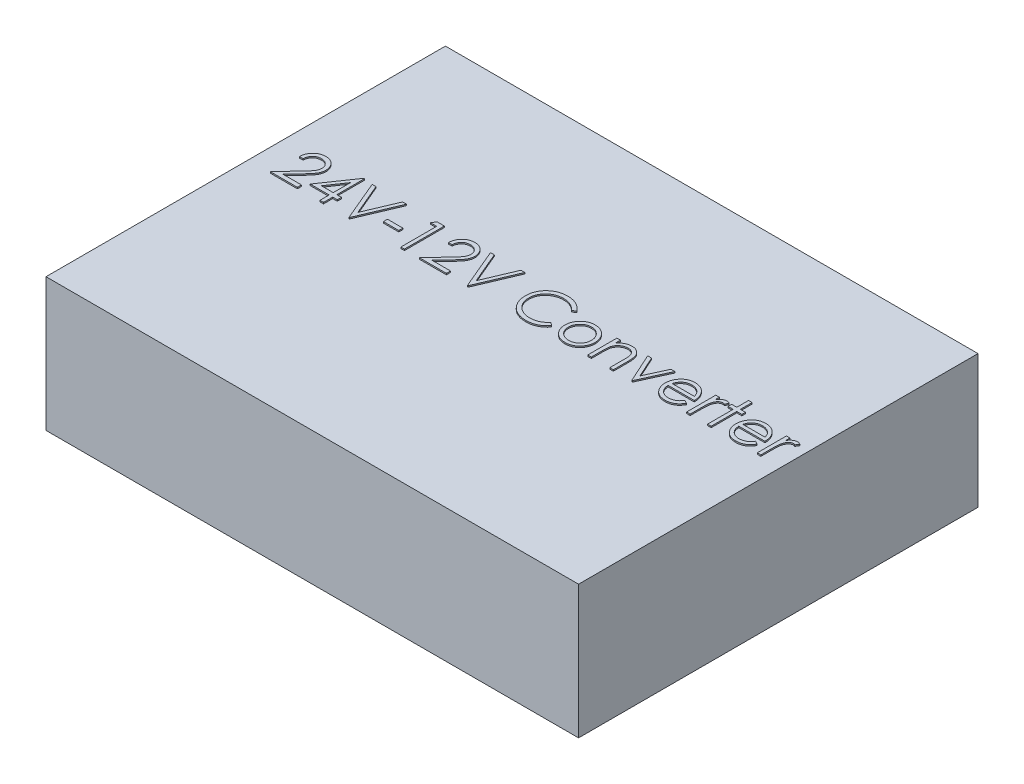
from build123d import *

# Parameters (mm, degrees)
SKETCH1_W           = 101.6
SKETCH1_H           = 76.2
BOSS_EXTRUDE1_DEPTH = 25.4
SKETCH2_W           = 2.930769231
SKETCH2_H           = 0.781538461
BOSS_EXTRUDE2_DEPTH = 0.254


with BuildPart() as part:
    # Sketch1 → Boss-Extrude1 (new body)
    with BuildSketch(Plane(origin=(0, 0, 0), x_dir=(1, 0, 0), z_dir=(0, 1, 0))):
        Rectangle(SKETCH1_W, SKETCH1_H)
    extrude(amount=BOSS_EXTRUDE1_DEPTH)

    # Sketch2 → Boss-Extrude2 (add)
    with BuildSketch(Plane(origin=(0, 25.4, 0), x_dir=(1, 0, 0), z_dir=(0, 1, 0))):
        with BuildLine():
            Line((-45.537178917, 5.672055623), (-46.221025071, 5.672055623))
            add(Edge.make_bspline(
                [(-46.221025071, 5.672055623), (-46.216568126, 5.762779099), (-46.207814806, 5.940957591), (-46.16682293, 6.200742781), (-46.108168792, 6.449056371), (-46.025238255, 6.683904584), (-45.92224573, 6.90736393), (-45.798736356, 7.118546821), (-45.652445745, 7.316647638), (-45.486532798, 7.49982992), (-45.306333647, 7.667878288), (-45.111901858, 7.812996274), (-44.907587828, 7.93560789), (-44.694011422, 8.038110479), (-44.468762995, 8.115050372), (-44.233886602, 8.172138628), (-43.98835031, 8.206485986), (-43.821058605, 8.210177954), (-43.735976994, 8.212055623)],
                knots=[0, 0, 0, 0, 0.000272323, 0.000534836, 0.000787701, 0.001036806, 0.001280626, 0.001524881, 0.001769426, 0.002018016, 0.00226538, 0.002507474, 0.002744387, 0.002979266, 0.003216773, 0.003457051, 0.00370358, 0.00395872, 0.00395872, 0.00395872, 0.00395872], degree=3))
            add(Edge.make_bspline(
                [(-43.735976994, 8.212055623), (-43.652422444, 8.210099555), (-43.488240738, 8.206255951), (-43.24862001, 8.173248225), (-43.020504871, 8.12155068), (-42.80434122, 8.049018259), (-42.601853731, 7.951516163), (-42.411521274, 7.834391236), (-42.231077908, 7.698929774), (-42.068648282, 7.539445757), (-41.919496407, 7.369187995), (-41.790822354, 7.187422902), (-41.680630267, 6.999689428), (-41.588781661, 6.804556029), (-41.52116801, 6.60018539), (-41.469834883, 6.389552909), (-41.440819199, 6.17047832), (-41.43636602, 6.022200619), (-41.434101994, 5.946815239)],
                knots=[0, 0, 0, 0, 0.000250564, 0.00049235, 0.000724148, 0.000951506, 0.001174769, 0.001396771, 0.001621163, 0.001850027, 0.002078347, 0.002299444, 0.002516998, 0.002730754, 0.002945077, 0.003161665, 0.003380352, 0.003606518, 0.003606518, 0.003606518, 0.003606518], degree=3))
            add(Edge.make_bspline(
                [(-41.434101994, 5.946815239), (-41.437788469, 5.840684239), (-41.445096727, 5.630284688), (-41.507612027, 5.321098044), (-41.605249288, 5.021537514), (-41.722809248, 4.780446588), (-41.84140354, 4.586172524), (-41.948274057, 4.426220658), (-42.07338316, 4.253996753), (-42.218551775, 4.070077521), (-42.380776943, 3.873022351), (-42.561528053, 3.662950282), (-42.762094033, 3.442031743), (-42.902864826, 3.291143548), (-42.975808725, 3.212957065)],
                knots=[0, 0, 0, 0, 0.00031812, 0.000630656, 0.000942484, 0.001261306, 0.001432513, 0.001625141, 0.001838259, 0.00207094, 0.00232795, 0.002603949, 0.002902235, 0.003223024, 0.003223024, 0.003223024, 0.003223024], degree=3))
            Line((-42.975808725, 3.212957065), (-44.882335167, 1.178209469))
            Line((-44.882335167, 1.178209469), (-41.336409686, 1.178209469))
            Line((-41.336409686, 1.178209469), (-41.336409686, 0.396671008))
            Line((-41.336409686, 0.396671008), (-46.514101994, 0.396671008))
            Line((-46.514101994, 0.396671008), (-43.558909686, 3.550300815))
            add(Edge.make_bspline(
                [(-43.558909686, 3.550300815), (-43.486959716, 3.625408557), (-43.348758547, 3.769675158), (-43.153289051, 3.980298402), (-42.977726454, 4.175695974), (-42.820934301, 4.355498688), (-42.686313927, 4.522336558), (-42.566849239, 4.67080617), (-42.471129867, 4.807431573), (-42.367246634, 4.965798281), (-42.266632194, 5.159155383), (-42.180172722, 5.39544873), (-42.127453538, 5.63869492), (-42.121129296, 5.803073641), (-42.117948148, 5.885757546)],
                knots=[0, 0, 0, 0, 0.000312026, 0.000599338, 0.000861997, 0.001100083, 0.001314883, 0.001505126, 0.001671571, 0.001815105, 0.002073178, 0.00232331, 0.002568198, 0.002816051, 0.002816051, 0.002816051, 0.002816051], degree=3))
            add(Edge.make_bspline(
                [(-42.117948148, 5.885757546), (-42.11933225, 5.937750762), (-42.122060048, 6.040219407), (-42.146134236, 6.190454802), (-42.182515395, 6.335375911), (-42.234647642, 6.475428505), (-42.30346003, 6.609204467), (-42.387222075, 6.736866638), (-42.483865584, 6.860286614), (-42.595664633, 6.976008937), (-42.718480571, 7.081994876), (-42.848225766, 7.17588217), (-42.98549485, 7.254344463), (-43.129709059, 7.318664877), (-43.280466338, 7.369120993), (-43.438058269, 7.404082814), (-43.602049413, 7.426033822), (-43.71402748, 7.429003819), (-43.771085167, 7.430517162)],
                knots=[0, 0, 0, 0, 0.000155884, 0.000307218, 0.000455306, 0.000603591, 0.000754462, 0.000905611, 0.001061046, 0.001224061, 0.001387476, 0.001547177, 0.001703754, 0.001860911, 0.002020203, 0.00217981, 0.002344531, 0.002515663, 0.002515663, 0.002515663, 0.002515663], degree=3))
            add(Edge.make_bspline(
                [(-43.771085167, 7.430517162), (-43.83067538, 7.428960434), (-43.947700719, 7.425903279), (-44.119518728, 7.404517936), (-44.283426621, 7.367624421), (-44.439836707, 7.317165489), (-44.589013634, 7.25303002), (-44.730231924, 7.17314685), (-44.863174557, 7.077823931), (-44.988091445, 6.969749348), (-45.103183879, 6.849423885), (-45.204305363, 6.715290194), (-45.29266256, 6.569797364), (-45.36975352, 6.413337971), (-45.432358765, 6.244492313), (-45.480197452, 6.063859767), (-45.518051101, 5.872224645), (-45.530697081, 5.739886832), (-45.537178917, 5.672055623)],
                knots=[0, 0, 0, 0, 0.000178757, 0.000351049, 0.000518436, 0.000682079, 0.000843428, 0.00100474, 0.001167813, 0.001333381, 0.001499658, 0.001666348, 0.00183625, 0.002009647, 0.00218884, 0.002375466, 0.002569756, 0.00277406, 0.00277406, 0.00277406, 0.00277406], degree=3))
        make_face()
        Polygon((-36.493008244, 8.212055623), (-36.354101994, 8.212055623), (-36.354101994, 2.936671008), (-35.474871225, 2.936671008), (-35.474871225, 2.155132546), (-36.354101994, 2.155132546), (-36.354101994, 0.396671008), (-37.037948148, 0.396671008), (-37.037948148, 2.155132546), (-40.652563532, 2.155132546), align=None)
        Polygon((-37.037948148, 2.936671008), (-37.037948148, 6.245997931), (-39.309294302, 2.936671008), align=None, mode=Mode.SUBTRACT)
        Polygon((-34.693332763, 8.016671008), (-33.960640455, 8.016671008), (-31.420640455, 2.011646969), (-28.880640455, 8.016671008), (-28.147948148, 8.016671008), (-31.371794302, 0.396671008), (-31.469486609, 0.396671008), align=None)
        with Locations((-25.998717379, 3.327440239)):
            Rectangle(SKETCH2_W, SKETCH2_H)
        Polygon((-22.327623629, 8.016671008), (-20.918717379, 8.016671008), (-20.918717379, 0.396671008), (-21.602563532, 0.396671008), (-21.602563532, 7.235132546), (-22.774871225, 7.235132546), align=None)
        with BuildLine():
            Line((-17.108717379, 5.672055623), (-17.792563532, 5.672055623))
            add(Edge.make_bspline(
                [(-17.792563532, 5.672055623), (-17.788106588, 5.762779099), (-17.779353267, 5.940957591), (-17.738361392, 6.200742781), (-17.679707254, 6.449056371), (-17.596776716, 6.683904584), (-17.493784192, 6.90736393), (-17.370274818, 7.118546821), (-17.223984206, 7.316647638), (-17.058071259, 7.49982992), (-16.877872108, 7.667878288), (-16.68344032, 7.812996274), (-16.479126289, 7.93560789), (-16.265549883, 8.038110479), (-16.040301456, 8.115050372), (-15.805425063, 8.172138628), (-15.559888772, 8.206485986), (-15.392597067, 8.210177954), (-15.307515455, 8.212055623)],
                knots=[0, 0, 0, 0, 0.000272323, 0.000534836, 0.000787701, 0.001036806, 0.001280626, 0.001524881, 0.001769426, 0.002018016, 0.00226538, 0.002507474, 0.002744387, 0.002979266, 0.003216773, 0.003457051, 0.00370358, 0.00395872, 0.00395872, 0.00395872, 0.00395872], degree=3))
            add(Edge.make_bspline(
                [(-15.307515455, 8.212055623), (-15.223960906, 8.210099555), (-15.0597792, 8.206255951), (-14.820158471, 8.173248225), (-14.592043333, 8.12155068), (-14.375879681, 8.049018259), (-14.173392192, 7.951516163), (-13.983059735, 7.834391236), (-13.80261637, 7.698929774), (-13.640186744, 7.539445757), (-13.491034869, 7.369187995), (-13.362360816, 7.187422902), (-13.252168729, 6.999689428), (-13.160320123, 6.804556029), (-13.092706472, 6.60018539), (-13.041373344, 6.389552909), (-13.012357661, 6.17047832), (-13.007904482, 6.022200619), (-13.005640455, 5.946815239)],
                knots=[0, 0, 0, 0, 0.000250564, 0.00049235, 0.000724148, 0.000951506, 0.001174769, 0.001396771, 0.001621163, 0.001850027, 0.002078347, 0.002299444, 0.002516998, 0.002730754, 0.002945077, 0.003161665, 0.003380352, 0.003606518, 0.003606518, 0.003606518, 0.003606518], degree=3))
            add(Edge.make_bspline(
                [(-13.005640455, 5.946815239), (-13.009326931, 5.840684239), (-13.016635188, 5.630284688), (-13.079150488, 5.321098044), (-13.17678775, 5.021537514), (-13.294347709, 4.780446588), (-13.412942002, 4.586172524), (-13.519812518, 4.426220658), (-13.644921621, 4.253996753), (-13.790090237, 4.070077521), (-13.952315404, 3.873022351), (-14.133066514, 3.662950282), (-14.333632495, 3.442031743), (-14.474403288, 3.291143548), (-14.547347186, 3.212957065)],
                knots=[0, 0, 0, 0, 0.00031812, 0.000630656, 0.000942484, 0.001261306, 0.001432513, 0.001625141, 0.001838259, 0.00207094, 0.00232795, 0.002603949, 0.002902235, 0.003223024, 0.003223024, 0.003223024, 0.003223024], degree=3))
            Line((-14.547347186, 3.212957065), (-16.453873629, 1.178209469))
            Line((-16.453873629, 1.178209469), (-12.907948148, 1.178209469))
            Line((-12.907948148, 1.178209469), (-12.907948148, 0.396671008))
            Line((-12.907948148, 0.396671008), (-18.085640455, 0.396671008))
            Line((-18.085640455, 0.396671008), (-15.130448148, 3.550300815))
            add(Edge.make_bspline(
                [(-15.130448148, 3.550300815), (-15.058498177, 3.625408557), (-14.920297008, 3.769675158), (-14.724827513, 3.980298402), (-14.549264915, 4.175695974), (-14.392472763, 4.355498688), (-14.257852388, 4.522336558), (-14.1383877, 4.67080617), (-14.042668328, 4.807431573), (-13.938785095, 4.965798281), (-13.838170656, 5.159155383), (-13.751711183, 5.39544873), (-13.698991999, 5.63869492), (-13.692667757, 5.803073641), (-13.689486609, 5.885757546)],
                knots=[0, 0, 0, 0, 0.000312026, 0.000599338, 0.000861997, 0.001100083, 0.001314883, 0.001505126, 0.001671571, 0.001815105, 0.002073178, 0.00232331, 0.002568198, 0.002816051, 0.002816051, 0.002816051, 0.002816051], degree=3))
            add(Edge.make_bspline(
                [(-13.689486609, 5.885757546), (-13.690870711, 5.937750762), (-13.69359851, 6.040219407), (-13.717672697, 6.190454802), (-13.754053856, 6.335375911), (-13.806186104, 6.475428505), (-13.874998492, 6.609204467), (-13.958760536, 6.736866638), (-14.055404046, 6.860286614), (-14.167203095, 6.976008937), (-14.290019032, 7.081994876), (-14.419764227, 7.17588217), (-14.557033311, 7.254344463), (-14.70124752, 7.318664877), (-14.852004799, 7.369120993), (-15.00959673, 7.404082814), (-15.173587874, 7.426033822), (-15.285565942, 7.429003819), (-15.342623629, 7.430517162)],
                knots=[0, 0, 0, 0, 0.000155884, 0.000307218, 0.000455306, 0.000603591, 0.000754462, 0.000905611, 0.001061046, 0.001224061, 0.001387476, 0.001547177, 0.001703754, 0.001860911, 0.002020203, 0.00217981, 0.002344531, 0.002515663, 0.002515663, 0.002515663, 0.002515663], degree=3))
            add(Edge.make_bspline(
                [(-15.342623629, 7.430517162), (-15.402213842, 7.428960434), (-15.519239181, 7.425903279), (-15.69105719, 7.404517936), (-15.854965082, 7.367624421), (-16.011375168, 7.317165489), (-16.160552095, 7.25303002), (-16.301770385, 7.17314685), (-16.434713018, 7.077823931), (-16.559629906, 6.969749348), (-16.674722341, 6.849423885), (-16.775843825, 6.715290194), (-16.864201021, 6.569797364), (-16.941291981, 6.413337971), (-17.003897226, 6.244492313), (-17.051735914, 6.063859767), (-17.089589563, 5.872224645), (-17.102235542, 5.739886832), (-17.108717379, 5.672055623)],
                knots=[0, 0, 0, 0, 0.000178757, 0.000351049, 0.000518436, 0.000682079, 0.000843428, 0.00100474, 0.001167813, 0.001333381, 0.001499658, 0.001666348, 0.00183625, 0.002009647, 0.00218884, 0.002375466, 0.002569756, 0.00277406, 0.00277406, 0.00277406, 0.00277406], degree=3))
        make_face()
        Polygon((-12.126409686, 8.016671008), (-11.393717379, 8.016671008), (-8.853717379, 2.011646969), (-6.313717379, 8.016671008), (-5.581025071, 8.016671008), (-8.804871225, 0.396671008), (-8.902563532, 0.396671008), align=None)
        with BuildLine():
            Line((5.751282621, 6.618449854), (5.152917237, 6.160517162))
            add(Edge.make_bspline(
                [(5.152917237, 6.160517162), (5.110232417, 6.211388216), (5.025438261, 6.312444472), (4.889020226, 6.454349652), (4.746849221, 6.58729745), (4.598979591, 6.711921199), (4.442749737, 6.823862843), (4.281944227, 6.92895593), (4.113873054, 7.023155977), (3.881459277, 7.137375393), (3.577425962, 7.256565593), (3.194695484, 7.356503485), (2.795165606, 7.420122159), (2.522592547, 7.427012471), (2.383950891, 7.430517162)],
                knots=[0, 0, 0, 0, 0.000199176, 0.000395666, 0.000590059, 0.000782959, 0.000975315, 0.001166267, 0.00135901, 0.001552886, 0.00194293, 0.002336139, 0.002737684, 0.00315335, 0.00315335, 0.00315335, 0.00315335], degree=3))
            add(Edge.make_bspline(
                [(2.383950891, 7.430517162), (2.307569536, 7.429637678), (2.155515718, 7.427886872), (1.929858184, 7.404789291), (1.708414342, 7.372325456), (1.491328235, 7.324155467), (1.278876194, 7.263255079), (1.069669307, 7.190483178), (0.866736516, 7.100447784), (0.667270523, 7.000934372), (0.47616264, 6.888534049), (0.295339936, 6.765931838), (0.125461903, 6.63449969), (-0.033605841, 6.493744996), (-0.182025911, 6.344301642), (-0.318722856, 6.18457699), (-0.443223664, 6.015081686), (-0.557996158, 5.838050782), (-0.660785024, 5.653999933), (-0.746847218, 5.462247922), (-0.82305837, 5.266078418), (-0.883363578, 5.063275033), (-0.931096383, 4.855264783), (-0.964031467, 4.641489411), (-0.986866368, 4.422395514), (-0.988608467, 4.273894096), (-0.989486609, 4.199038796)],
                knots=[0, 0, 0, 0, 0.000229048, 0.00045597, 0.000679837, 0.000900206, 0.001122459, 0.001342606, 0.001564087, 0.001787996, 0.002011045, 0.002228658, 0.002442997, 0.002654947, 0.002865424, 0.003074369, 0.003285023, 0.003495877, 0.003707001, 0.003916708, 0.004125919, 0.004337919, 0.00455084, 0.004765657, 0.004986501, 0.005210971, 0.005210971, 0.005210971, 0.005210971], degree=3))
            add(Edge.make_bspline(
                [(-0.989486609, 4.199038796), (-0.986739449, 4.086412323), (-0.981345764, 3.865285181), (-0.933343391, 3.541390309), (-0.860398021, 3.231102442), (-0.751071536, 2.936361185), (-0.616264918, 2.653532131), (-0.445923929, 2.387400685), (-0.248638782, 2.133945193), (-0.021618475, 1.899155689), (0.22745933, 1.684677236), (0.494699069, 1.495808827), (0.779435147, 1.338368997), (1.078523697, 1.207357365), (1.394266265, 1.106649861), (1.726095063, 1.035753112), (2.073288378, 0.98950585), (2.310530329, 0.985078221), (2.431270602, 0.982824854)],
                knots=[0, 0, 0, 0, 0.000337689, 0.000663007, 0.000980291, 0.001292238, 0.001604234, 0.001918459, 0.00223816, 0.002566349, 0.002896488, 0.003222997, 0.003546206, 0.003870912, 0.004201103, 0.00453853, 0.004887849, 0.005249876, 0.005249876, 0.005249876, 0.005249876], degree=3))
            add(Edge.make_bspline(
                [(2.431270602, 0.982824854), (2.564299885, 0.986501569), (2.826133337, 0.993738223), (3.210111726, 1.055044931), (3.577691307, 1.154448741), (3.928891853, 1.293563646), (4.262723282, 1.474408644), (4.579708011, 1.693642309), (4.880113602, 1.95335005), (5.060753936, 2.151651032), (5.152917237, 2.252824854)],
                knots=[0, 0, 0, 0, 0.000398895, 0.000785121, 0.001163193, 0.001539336, 0.001915653, 0.002299692, 0.002693579, 0.003103877, 0.003103877, 0.003103877, 0.003103877], degree=3))
            Line((5.152917237, 2.252824854), (5.751282621, 1.799471489))
            add(Edge.make_bspline(
                [(5.751282621, 1.799471489), (5.703128337, 1.737339202), (5.607050423, 1.613372238), (5.451476112, 1.438609259), (5.287586681, 1.274226187), (5.114164821, 1.121548338), (4.933205515, 0.977520615), (4.741459509, 0.846234914), (4.541447501, 0.72585876), (4.333847179, 0.615636713), (4.118879113, 0.51784545), (3.896800886, 0.434126104), (3.668569748, 0.362008487), (3.434175264, 0.302677128), (3.193131244, 0.25636694), (2.946307526, 0.225408676), (2.693171398, 0.204199137), (2.522393218, 0.202266017), (2.435849929, 0.201286392)],
                knots=[0, 0, 0, 0, 0.00023577, 0.00047041, 0.000701393, 0.000931724, 0.001163205, 0.001394807, 0.001628318, 0.001863212, 0.002099574, 0.002336295, 0.002574782, 0.002817275, 0.003061263, 0.003310615, 0.003563259, 0.003822826, 0.003822826, 0.003822826, 0.003822826], degree=3))
            add(Edge.make_bspline(
                [(2.435849929, 0.201286392), (2.353894288, 0.201856788), (2.191837157, 0.202984674), (1.952571875, 0.221255621), (1.719640274, 0.246183334), (1.493708088, 0.283717562), (1.273542394, 0.328010097), (1.061139064, 0.387383518), (0.854408006, 0.453893418), (0.65417979, 0.532063703), (0.460284101, 0.620273221), (0.273346317, 0.719967986), (0.093452416, 0.830309646), (-0.081166243, 0.948865983), (-0.247930125, 1.079445137), (-0.408284372, 1.220233639), (-0.563128163, 1.370756965), (-0.658928294, 1.479298103), (-0.707094782, 1.533870527)],
                knots=[0, 0, 0, 0, 0.0002458, 0.000486039, 0.000719505, 0.000948369, 0.001172896, 0.001392858, 0.001609596, 0.00182418, 0.002037297, 0.002248306, 0.002459308, 0.002670156, 0.002881148, 0.003094244, 0.003310126, 0.003528424, 0.003528424, 0.003528424, 0.003528424], degree=3))
            add(Edge.make_bspline(
                [(-0.707094782, 1.533870527), (-0.784243241, 1.628665915), (-0.937608753, 1.817112239), (-1.133825241, 2.122534861), (-1.30178649, 2.441417076), (-1.43758778, 2.775434178), (-1.543751216, 3.123836661), (-1.617297704, 3.486800153), (-1.665089483, 3.863985672), (-1.67055474, 4.120533195), (-1.673332763, 4.250937835)],
                knots=[0, 0, 0, 0, 0.000366426, 0.000728427, 0.001086882, 0.001446309, 0.001808466, 0.002177883, 0.00255617, 0.002947238, 0.002947238, 0.002947238, 0.002947238], degree=3))
            add(Edge.make_bspline(
                [(-1.673332763, 4.250937835), (-1.669946885, 4.388000851), (-1.66328538, 4.657663778), (-1.60668882, 5.053411642), (-1.515643326, 5.432564116), (-1.386327814, 5.794413411), (-1.222377307, 6.140862764), (-1.019845079, 6.469265616), (-0.781084043, 6.781722191), (-0.507966768, 7.07349145), (-0.208463026, 7.340277126), (0.112271077, 7.574986633), (0.453607773, 7.770314482), (0.811786639, 7.933591841), (1.189489751, 8.059092072), (1.585911258, 8.146946724), (2.000306267, 8.201630275), (2.283035319, 8.208543156), (2.426691275, 8.212055623)],
                knots=[0, 0, 0, 0, 0.000411021, 0.000808659, 0.001196655, 0.001579034, 0.001959341, 0.002344444, 0.002734312, 0.003137157, 0.003541534, 0.003936009, 0.004327172, 0.004719298, 0.005115115, 0.005518766, 0.005935868, 0.006366714, 0.006366714, 0.006366714, 0.006366714], degree=3))
            add(Edge.make_bspline(
                [(2.426691275, 8.212055623), (2.514243926, 8.211005939), (2.68754558, 8.208928196), (2.943909926, 8.188667395), (3.193502649, 8.154892058), (3.436495701, 8.108919358), (3.674071226, 8.051862275), (3.904413465, 7.977533968), (4.128874034, 7.892545863), (4.346037303, 7.79466486), (4.554861335, 7.684791555), (4.755281091, 7.564143826), (4.945704584, 7.432871243), (5.127471734, 7.292090273), (5.297541885, 7.138822552), (5.460743732, 6.977283786), (5.611534994, 6.802821003), (5.704614807, 6.680019404), (5.751282621, 6.618449854)],
                knots=[0, 0, 0, 0, 0.000262619, 0.000519828, 0.000770894, 0.001017881, 0.001261486, 0.001503344, 0.001743462, 0.001981214, 0.002217458, 0.002450969, 0.002682571, 0.002910967, 0.003140157, 0.003368981, 0.003599453, 0.003831196, 0.003831196, 0.003831196, 0.003831196], degree=3))
        make_face()
        with BuildLine():
            add(Edge.make_bspline(
                [(9.808566275, 6.062824854), (9.913050132, 6.060600051), (10.117917441, 6.056237756), (10.417944895, 6.009614316), (10.704337448, 5.938318626), (10.978191958, 5.839755968), (11.23600115, 5.707642693), (11.481520259, 5.549997322), (11.714076147, 5.363236361), (11.853463427, 5.218765366), (11.924215314, 5.145433027)],
                knots=[0, 0, 0, 0, 0.000313222, 0.000614152, 0.000908474, 0.00119773, 0.001485127, 0.001775589, 0.002071911, 0.002377372, 0.002377372, 0.002377372, 0.002377372], degree=3))
            add(Edge.make_bspline(
                [(11.924215314, 5.145433027), (11.985136025, 5.075298578), (12.105798464, 4.936386975), (12.260518686, 4.711149326), (12.393806769, 4.477890021), (12.500623844, 4.233511556), (12.584846667, 3.980147272), (12.644643411, 3.716926322), (12.680211253, 3.444430011), (12.685007426, 3.259364513), (12.687436468, 3.165637354)],
                knots=[0, 0, 0, 0, 0.000278504, 0.000551617, 0.000818199, 0.001083383, 0.001350318, 0.001618043, 0.001892008, 0.002173139, 0.002173139, 0.002173139, 0.002173139], degree=3))
            add(Edge.make_bspline(
                [(12.687436468, 3.165637354), (12.685299956, 3.071366943), (12.68107811, 2.885084214), (12.641141436, 2.610722051), (12.579025186, 2.344686466), (12.490128442, 2.088091253), (12.376137358, 1.840152069), (12.237038204, 1.60195185), (12.071854855, 1.373020634), (11.884611867, 1.155302346), (11.677670354, 0.95464333), (11.453171768, 0.779757212), (11.215527844, 0.629922921), (10.9615786, 0.509229925), (10.6936431, 0.414067663), (10.411143426, 0.347229342), (10.114518445, 0.306817905), (9.911984894, 0.301628525), (9.808566275, 0.2989787)],
                knots=[0, 0, 0, 0, 0.000282656, 0.000558541, 0.00082993, 0.001101225, 0.001371698, 0.001647376, 0.001927386, 0.002217458, 0.002507856, 0.002790606, 0.003069716, 0.003348959, 0.003632355, 0.00392114, 0.004218404, 0.004528576, 0.004528576, 0.004528576, 0.004528576], degree=3))
            add(Edge.make_bspline(
                [(9.808566275, 0.2989787), (9.704640972, 0.301637419), (9.501098014, 0.306844653), (9.203426019, 0.347072338), (8.920420049, 0.41403686), (8.652133786, 0.509542658), (8.397092719, 0.629926779), (8.158071831, 0.779304229), (7.933390873, 0.954695195), (7.726405581, 1.155288293), (7.539174331, 1.373024255), (7.373987953, 1.60195091), (7.234889586, 1.840152313), (7.120898296, 2.088091187), (7.032001607, 2.344686484), (6.969885342, 2.610722047), (6.929948673, 2.885084215), (6.925726826, 3.071366943), (6.923590314, 3.165637354)],
                knots=[0, 0, 0, 0, 0.000311697, 0.000610475, 0.000899259, 0.001182655, 0.001463276, 0.001743681, 0.002026431, 0.002316828, 0.002606901, 0.00288691, 0.003162588, 0.003433062, 0.003704357, 0.003975746, 0.004251631, 0.004534287, 0.004534287, 0.004534287, 0.004534287], degree=3))
            add(Edge.make_bspline(
                [(6.923590314, 3.165637354), (6.926035921, 3.258855091), (6.930877803, 3.44341019), (6.966409882, 3.715394248), (7.025973368, 3.978169706), (7.110297151, 4.230556028), (7.218098796, 4.473863578), (7.349513942, 4.707699238), (7.505812405, 4.931918392), (7.62599494, 5.070650464), (7.686811468, 5.1408537)],
                knots=[0, 0, 0, 0, 0.000279606, 0.000553571, 0.000821296, 0.001086782, 0.00135057, 0.001618481, 0.001890342, 0.002168846, 0.002168846, 0.002168846, 0.002168846], degree=3))
            add(Edge.make_bspline(
                [(7.686811468, 5.1408537), (7.757456686, 5.214821996), (7.896392938, 5.360293666), (8.130106454, 5.54651019), (8.375021573, 5.707436043), (8.635679841, 5.83692426), (8.909309377, 5.938898404), (9.197169557, 6.009798183), (9.498215107, 6.056069773), (9.704084911, 6.06055072), (9.808566275, 6.062824854)],
                knots=[0, 0, 0, 0, 0.000306538, 0.00060286, 0.000894151, 0.001184275, 0.001474058, 0.001768381, 0.00207233, 0.002385553, 0.002385553, 0.002385553, 0.002385553], degree=3))
        make_face()
        with BuildLine():
            add(Edge.make_bspline(
                [(9.805513391, 5.3789787), (9.731626363, 5.376878646), (9.585759688, 5.372732751), (9.371050764, 5.341199221), (9.164352486, 5.291239227), (8.965272705, 5.220255539), (8.77448277, 5.128600221), (8.591800014, 5.016023734), (8.416687102, 4.884017126), (8.252569581, 4.732786967), (8.101949804, 4.567587556), (7.970280609, 4.391569129), (7.858320806, 4.207586741), (7.76505166, 4.01544907), (7.695585154, 3.813209014), (7.645134173, 3.603156897), (7.613630393, 3.384864762), (7.609523477, 3.236468488), (7.607436468, 3.161058027)],
                knots=[0, 0, 0, 0, 0.000221592, 0.000437463, 0.0006496, 0.000858656, 0.001070304, 0.001283405, 0.001501382, 0.001727177, 0.001951943, 0.00217114, 0.002385544, 0.002597192, 0.002810566, 0.00302567, 0.003244564, 0.00347073, 0.00347073, 0.00347073, 0.00347073], degree=3))
            add(Edge.make_bspline(
                [(7.607436468, 3.161058027), (7.610934752, 3.063626471), (7.617878193, 2.870243051), (7.674342908, 2.585448549), (7.768801037, 2.312038917), (7.896353915, 2.051616957), (8.056169739, 1.810667597), (8.244464439, 1.59584568), (8.459217158, 1.410383999), (8.697867938, 1.256501701), (8.955542196, 1.13423389), (9.228243101, 1.047585834), (9.512666555, 0.991259464), (9.707043461, 0.985660997), (9.805513391, 0.982824854)],
                knots=[0, 0, 0, 0, 0.000292125, 0.000579814, 0.000867033, 0.001157847, 0.001447425, 0.001731888, 0.002012193, 0.002295869, 0.002581281, 0.002865126, 0.003152527, 0.003447608, 0.003447608, 0.003447608, 0.003447608], degree=3))
            add(Edge.make_bspline(
                [(9.805513391, 0.982824854), (9.903977657, 0.985677521), (10.098343383, 0.991308607), (10.382371648, 1.047302152), (10.654327209, 1.13461355), (10.91173383, 1.25636419), (11.150275978, 1.410968362), (11.366573208, 1.594798417), (11.553260184, 1.811236573), (11.712917919, 2.051936108), (11.842559684, 2.311635183), (11.936575683, 2.585499011), (11.993176142, 2.870230199), (12.00010126, 3.063622165), (12.003590314, 3.161058027)],
                knots=[0, 0, 0, 0, 0.000295081, 0.000582483, 0.000864874, 0.001150287, 0.001433963, 0.001715425, 0.001998883, 0.002288461, 0.002579951, 0.00286717, 0.003154859, 0.003446984, 0.003446984, 0.003446984, 0.003446984], degree=3))
            add(Edge.make_bspline(
                [(12.003590314, 3.161058027), (12.001504023, 3.236468938), (11.997398521, 3.384866099), (11.965884456, 3.603151784), (11.915471538, 3.813227774), (11.84586476, 4.01537985), (11.753000879, 4.208084217), (11.638882032, 4.391028937), (11.507750485, 4.568197303), (11.355313211, 4.732252944), (11.191366999, 4.88407608), (11.016183116, 5.016074922), (10.833771248, 5.128105459), (10.643535591, 5.221039503), (10.444430287, 5.290593426), (10.238021623, 5.341487693), (10.024228785, 5.372599492), (9.878884811, 5.376838697), (9.805513391, 5.3789787)],
                knots=[0, 0, 0, 0, 0.000226166, 0.00044506, 0.000660164, 0.000873539, 0.001085186, 0.001300388, 0.001519585, 0.00174538, 0.001971175, 0.002189151, 0.002402253, 0.002612525, 0.00282302, 0.003033674, 0.003249546, 0.003469613, 0.003469613, 0.003469613, 0.003469613], degree=3))
        make_face(mode=Mode.SUBTRACT)
        with BuildLine():
            Line((14.055128775, 5.965132546), (14.738974929, 5.965132546))
            Line((14.738974929, 5.965132546), (14.738974929, 4.960733508))
            add(Edge.make_bspline(
                [(14.738974929, 4.960733508), (14.811991152, 5.051831093), (14.95368168, 5.228609135), (15.189649857, 5.460955072), (15.439028291, 5.65242439), (15.700289796, 5.805050365), (15.973789035, 5.920105019), (16.257858868, 6.003197703), (16.554200029, 6.053021244), (16.755726031, 6.059531403), (16.857676852, 6.062824854)],
                knots=[0, 0, 0, 0, 0.000350035, 0.000679255, 0.000990664, 0.001290955, 0.001584389, 0.001878565, 0.00217719, 0.00248294, 0.00248294, 0.00248294, 0.00248294], degree=3))
            add(Edge.make_bspline(
                [(16.857676852, 6.062824854), (16.960722404, 6.059025314), (17.162407405, 6.051588698), (17.456056213, 5.992769502), (17.730318288, 5.89230469), (17.984215721, 5.754682982), (18.213092682, 5.58354546), (18.414097073, 5.384167547), (18.580350772, 5.154835845), (18.691814745, 4.942078574), (18.765240298, 4.753344684), (18.81146613, 4.591698903), (18.850722152, 4.411609671), (18.884754701, 4.213621194), (18.907782584, 3.996346277), (18.925944945, 3.760675587), (18.938961416, 3.506685463), (18.93947785, 3.331019149), (18.93974416, 3.240433027)],
                knots=[0, 0, 0, 0, 0.000308979, 0.000604747, 0.000894003, 0.001182238, 0.001467988, 0.001748621, 0.00202829, 0.00231437, 0.002466594, 0.002635174, 0.002818125, 0.003019384, 0.00323751, 0.003473295, 0.003728503, 0.004000227, 0.004000227, 0.004000227, 0.004000227], degree=3))
            Line((18.93974416, 3.240433027), (18.93974416, 0.396671008))
            Line((18.93974416, 0.396671008), (18.255898006, 0.396671008))
            Line((18.255898006, 0.396671008), (18.255898006, 3.016046008))
            add(Edge.make_bspline(
                [(18.255898006, 3.016046008), (18.255477365, 3.091859445), (18.254672749, 3.236877648), (18.25213497, 3.444509636), (18.246017619, 3.632803272), (18.237421578, 3.801308398), (18.224839803, 3.949863207), (18.211727674, 4.078770261), (18.195693068, 4.187865894), (18.181404668, 4.253539587), (18.174996564, 4.282993123)],
                knots=[0, 0, 0, 0, 0.000227445, 0.000435064, 0.000622915, 0.000792598, 0.000941165, 0.00107012, 0.001181299, 0.001271708, 0.001271708, 0.001271708, 0.001271708], degree=3))
            add(Edge.make_bspline(
                [(18.174996564, 4.282993123), (18.151863264, 4.369450046), (18.107338819, 4.535852873), (17.997319118, 4.761566749), (17.85838653, 4.953586804), (17.688791784, 5.110725838), (17.490173053, 5.233017773), (17.263081503, 5.317869641), (17.009708576, 5.370940261), (16.831499892, 5.376224474), (16.738614352, 5.3789787)],
                knots=[0, 0, 0, 0, 0.000267998, 0.000515814, 0.00074846, 0.000975289, 0.001204891, 0.001443583, 0.001699242, 0.001977562, 0.001977562, 0.001977562, 0.001977562], degree=3))
            add(Edge.make_bspline(
                [(16.738614352, 5.3789787), (16.683602995, 5.37794237), (16.574736941, 5.375891499), (16.41330186, 5.355314673), (16.25671266, 5.321659407), (16.103397805, 5.276225402), (15.956423694, 5.213823547), (15.811068294, 5.143002461), (15.672804996, 5.054723211), (15.5386856, 4.956336773), (15.413907431, 4.847307184), (15.297804019, 4.732257137), (15.194306958, 4.609737108), (15.100540299, 4.481721222), (15.019597909, 4.346451335), (14.9489429, 4.205232473), (14.888993759, 4.057878766), (14.859204583, 3.955607347), (14.844299448, 3.904435431)],
                knots=[0, 0, 0, 0, 0.000164969, 0.000326469, 0.000487239, 0.000645143, 0.000805303, 0.000965725, 0.001129631, 0.001296628, 0.001464349, 0.001626253, 0.001786522, 0.001944986, 0.002101794, 0.002258802, 0.002418386, 0.002578197, 0.002578197, 0.002578197, 0.002578197], degree=3))
            add(Edge.make_bspline(
                [(14.844299448, 3.904435431), (14.835722271, 3.866868389), (14.817050203, 3.785086903), (14.796882937, 3.650878196), (14.778578445, 3.495626193), (14.763257981, 3.319512063), (14.753884474, 3.121919203), (14.743664101, 2.903691465), (14.739943231, 2.663958671), (14.739306735, 2.497055214), (14.738974929, 2.410048412)],
                knots=[0, 0, 0, 0, 0.000115567, 0.000251583, 0.000406838, 0.000584562, 0.000781763, 0.001000236, 0.001239931, 0.001500958, 0.001500958, 0.001500958, 0.001500958], degree=3))
            Line((14.738974929, 2.410048412), (14.738974929, 0.396671008))
            Line((14.738974929, 0.396671008), (14.055128775, 0.396671008))
            Line((14.055128775, 0.396671008), (14.055128775, 5.965132546))
        make_face()
        Polygon((19.916667237, 5.965132546), (20.656991756, 5.965132546), (22.505513391, 1.910901777), (24.354035025, 5.965132546), (25.094359545, 5.965132546), (22.554359545, 0.396671008), (22.456667237, 0.396671008), align=None)
        with BuildLine():
            Line((30.836835506, 2.155132546), (31.444359545, 1.836106104))
            add(Edge.make_bspline(
                [(31.444359545, 1.836106104), (31.3959473, 1.750232337), (31.301756244, 1.583155993), (31.139775187, 1.353615771), (30.969975303, 1.147118744), (30.784691807, 0.969181611), (30.589468106, 0.814057167), (30.383221583, 0.678338817), (30.1648785, 0.56269221), (29.934428528, 0.465259564), (29.689936362, 0.39034518), (29.430809518, 0.337431419), (29.156551577, 0.304723617), (28.968563608, 0.300924196), (28.872304256, 0.2989787)],
                knots=[0, 0, 0, 0, 0.000295567, 0.000575056, 0.000841637, 0.001096402, 0.001344091, 0.001588798, 0.001835992, 0.002084334, 0.002338302, 0.002601745, 0.002876852, 0.003165547, 0.003165547, 0.003165547, 0.003165547], degree=3))
            add(Edge.make_bspline(
                [(28.872304256, 0.2989787), (28.765315151, 0.301476265), (28.556610401, 0.30634829), (28.252812437, 0.348350741), (27.966780675, 0.416870562), (27.698531195, 0.512589826), (27.448720919, 0.637617315), (27.216853344, 0.789929101), (27.001709119, 0.968742752), (26.810067841, 1.175607124), (26.637542588, 1.396983271), (26.485304088, 1.627664368), (26.35803391, 1.867070017), (26.254505084, 2.113676129), (26.170892207, 2.365928377), (26.112617269, 2.626121915), (26.079024503, 2.89355253), (26.073876768, 3.074467301), (26.071282621, 3.165637354)],
                knots=[0, 0, 0, 0, 0.000320847, 0.00062588, 0.000917989, 0.001201899, 0.001478371, 0.001753986, 0.002032489, 0.002315413, 0.002598163, 0.002873778, 0.003143509, 0.003410288, 0.003675296, 0.003939705, 0.004208935, 0.004482441, 0.004482441, 0.004482441, 0.004482441], degree=3))
            add(Edge.make_bspline(
                [(26.071282621, 3.165637354), (26.073588523, 3.251187813), (26.078158517, 3.420737526), (26.106963831, 3.671687083), (26.158014115, 3.915589028), (26.228066569, 4.152646026), (26.318529567, 4.382461164), (26.42919857, 4.605174308), (26.560245976, 4.82054847), (26.661423625, 4.956409007), (26.712388391, 5.024844085)],
                knots=[0, 0, 0, 0, 0.000256665, 0.000508676, 0.000756552, 0.00100335, 0.001249392, 0.00149651, 0.001748614, 0.002004492, 0.002004492, 0.002004492, 0.002004492], degree=3))
            add(Edge.make_bspline(
                [(26.712388391, 5.024844085), (26.781420546, 5.107290025), (26.917298092, 5.269570227), (27.147109357, 5.482795953), (27.395957213, 5.661416972), (27.660723097, 5.809478223), (27.94448422, 5.921979134), (28.243426162, 6.005815642), (28.560952839, 6.052794054), (28.778025348, 6.059429624), (28.889095121, 6.062824854)],
                knots=[0, 0, 0, 0, 0.000322372, 0.000634532, 0.000937434, 0.001239442, 0.001542171, 0.001851029, 0.002169017, 0.002502205, 0.002502205, 0.002502205, 0.002502205], degree=3))
            add(Edge.make_bspline(
                [(28.889095121, 6.062824854), (29.003281051, 6.059876896), (29.227287815, 6.054093675), (29.553929175, 6.000478629), (29.862997935, 5.915455639), (30.154370416, 5.795377958), (30.428076159, 5.640453448), (30.682336072, 5.448556067), (30.921498508, 5.22557726), (31.060636614, 5.054098501), (31.131438871, 4.966839277)],
                knots=[0, 0, 0, 0, 0.000342335, 0.000671583, 0.000990084, 0.001302184, 0.001614583, 0.001930863, 0.002255894, 0.002592658, 0.002592658, 0.002592658, 0.002592658], degree=3))
            add(Edge.make_bspline(
                [(31.131438871, 4.966839277), (31.179612377, 4.901081766), (31.275638731, 4.770004444), (31.39591956, 4.556271811), (31.50032966, 4.332656174), (31.583785993, 4.095542899), (31.651363421, 3.847741413), (31.700255124, 3.587480215), (31.728927265, 3.314836808), (31.734563228, 3.129068707), (31.737436468, 3.034363315)],
                knots=[0, 0, 0, 0, 0.00024435, 0.000487074, 0.000734305, 0.00098392, 0.001240162, 0.001504214, 0.001777465, 0.002061645, 0.002061645, 0.002061645, 0.002061645], degree=3))
            Line((31.737436468, 3.034363315), (26.755128775, 3.034363315))
            add(Edge.make_bspline(
                [(26.755128775, 3.034363315), (26.758480718, 2.96099259), (26.765072179, 2.816712019), (26.795802863, 2.605592771), (26.844241621, 2.404482809), (26.912318838, 2.214890586), (26.99476037, 2.034339851), (27.095748701, 1.864169931), (27.216230816, 1.705155923), (27.350616482, 1.555875469), (27.500201643, 1.422937469), (27.65757151, 1.303952745), (27.824979786, 1.204227417), (28.001106471, 1.123281486), (28.185666757, 1.059912878), (28.378718793, 1.016657794), (28.579882692, 0.987686321), (28.717011633, 0.984464879), (28.786823487, 0.982824854)],
                knots=[0, 0, 0, 0, 0.000220237, 0.000433086, 0.00063893, 0.000839772, 0.00103647, 0.001233593, 0.001432031, 0.001634104, 0.001835155, 0.002031456, 0.002225176, 0.002418462, 0.002612031, 0.002809392, 0.003011234, 0.003220558, 0.003220558, 0.003220558, 0.003220558], degree=3))
            add(Edge.make_bspline(
                [(28.786823487, 0.982824854), (28.855079414, 0.98414868), (28.990512267, 0.986775405), (29.192204648, 1.012317451), (29.390628419, 1.053618451), (29.584962331, 1.109984658), (29.771262287, 1.178731976), (29.94379117, 1.261687341), (30.102461811, 1.353453361), (30.250762178, 1.45841271), (30.394608169, 1.586881963), (30.537303526, 1.747197447), (30.690305839, 1.936799436), (30.786077467, 2.079501715), (30.836835506, 2.155132546)],
                knots=[0, 0, 0, 0, 0.000204686, 0.000406136, 0.000608808, 0.000812192, 0.001012644, 0.001203816, 0.00138577, 0.001561973, 0.001747936, 0.001962948, 0.002205152, 0.002478266, 0.002478266, 0.002478266, 0.002478266], degree=3))
        make_face()
        with BuildLine():
            add(Edge.make_bspline(
                [(31.053590314, 3.718209469), (31.02856052, 3.808915497), (30.980386223, 3.983495403), (30.879723053, 4.225247284), (30.76635587, 4.440104943), (30.632196558, 4.62642403), (30.480191218, 4.791894535), (30.304615134, 4.936497283), (30.107723275, 5.065857563), (29.890533374, 5.175046719), (29.660536117, 5.26798864), (29.419730636, 5.330309606), (29.174023109, 5.373002381), (29.007832463, 5.37697808), (28.924203295, 5.3789787)],
                knots=[0, 0, 0, 0, 0.000282033, 0.000542822, 0.000783913, 0.001009269, 0.001229627, 0.001456143, 0.001689843, 0.001934922, 0.002184363, 0.002432442, 0.002679876, 0.00293051, 0.00293051, 0.00293051, 0.00293051], degree=3))
            add(Edge.make_bspline(
                [(28.924203295, 5.3789787), (28.855951088, 5.377647004), (28.721030826, 5.37501452), (28.522255358, 5.35004241), (28.331364127, 5.308764119), (28.146948616, 5.252234699), (27.971425468, 5.176886828), (27.801184287, 5.088531346), (27.640553824, 4.98067224), (27.540097632, 4.898465819), (27.489347525, 4.856935431)],
                knots=[0, 0, 0, 0, 0.000204686, 0.00040462, 0.000599826, 0.00079005, 0.000982267, 0.001172087, 0.001364715, 0.001561389, 0.001561389, 0.001561389, 0.001561389], degree=3))
            add(Edge.make_bspline(
                [(27.489347525, 4.856935431), (27.453003866, 4.824072949), (27.379453156, 4.757567296), (27.281175792, 4.642985995), (27.187078649, 4.519429737), (27.101443668, 4.382171494), (27.022897608, 4.232774255), (26.949397315, 4.072498147), (26.883241755, 3.900126932), (26.846021081, 3.78000865), (26.826871564, 3.718209469)],
                knots=[0, 0, 0, 0, 0.000146856, 0.000297201, 0.000451983, 0.000612491, 0.000781837, 0.000958067, 0.001141195, 0.001335252, 0.001335252, 0.001335252, 0.001335252], degree=3))
            Line((26.826871564, 3.718209469), (31.053590314, 3.718209469))
        make_face(mode=Mode.SUBTRACT)
        with BuildLine():
            Line((32.90974416, 5.965132546), (33.593590314, 5.965132546))
            Line((33.593590314, 5.965132546), (33.593590314, 5.145433027))
            add(Edge.make_bspline(
                [(33.593590314, 5.145433027), (33.644075554, 5.221754573), (33.740628184, 5.367718937), (33.901111762, 5.560764673), (34.0654933, 5.720599717), (34.234559737, 5.847970235), (34.409554343, 5.943357654), (34.586636506, 6.013228776), (34.768592244, 6.054545102), (34.890864776, 6.06006124), (34.952123968, 6.062824854)],
                knots=[0, 0, 0, 0, 0.000274369, 0.000524729, 0.000751435, 0.000960864, 0.001157609, 0.001347533, 0.001530484, 0.001714171, 0.001714171, 0.001714171, 0.001714171], degree=3))
            add(Edge.make_bspline(
                [(34.952123968, 6.062824854), (34.999642998, 6.060232907), (35.097416492, 6.054899809), (35.245424302, 6.017429385), (35.397918903, 5.957605805), (35.496200329, 5.901347948), (35.547436468, 5.872019565)],
                knots=[0, 0, 0, 0, 0.000142483, 0.000293169, 0.00045559, 0.000632479, 0.000632479, 0.000632479, 0.000632479], degree=3))
            Line((35.547436468, 5.872019565), (35.17193166, 5.27975995))
            add(Edge.make_bspline(
                [(35.17193166, 5.27975995), (35.139037162, 5.294434472), (35.076597109, 5.322289525), (34.985256025, 5.355255844), (34.901041229, 5.374667066), (34.847388682, 5.377607771), (34.822376371, 5.3789787)],
                knots=[0, 0, 0, 0, 0.000108033, 0.000205067, 0.000290996, 0.000366041, 0.000366041, 0.000366041, 0.000366041], degree=3))
            add(Edge.make_bspline(
                [(34.822376371, 5.3789787), (34.767499889, 5.375321019), (34.655567771, 5.367860409), (34.491227232, 5.309210776), (34.331757602, 5.21445011), (34.205109583, 5.109357004), (34.107046164, 5.008015799), (34.037072302, 4.91951842), (33.97288415, 4.820287228), (33.911553555, 4.712018602), (33.855674366, 4.592863909), (33.803521629, 4.464013598), (33.756367191, 4.325318432), (33.729478945, 4.228691345), (33.715705698, 4.179195046)],
                knots=[0, 0, 0, 0, 0.000164353, 0.000335233, 0.000517187, 0.000718886, 0.000826843, 0.000939841, 0.001056691, 0.001181084, 0.001312863, 0.00145119, 0.001597935, 0.001752045, 0.001752045, 0.001752045, 0.001752045], degree=3))
            add(Edge.make_bspline(
                [(33.715705698, 4.179195046), (33.705402602, 4.135048743), (33.682582026, 4.037268035), (33.660393593, 3.873223532), (33.638470813, 3.67940631), (33.623020461, 3.45527687), (33.608699124, 3.201394921), (33.600621745, 2.917373691), (33.593865765, 2.602921652), (33.593684916, 2.38308606), (33.593590314, 2.268089277)],
                knots=[0, 0, 0, 0, 0.000135931, 0.000301076, 0.000496108, 0.000721123, 0.000974884, 0.00125895, 0.001573457, 0.001918436, 0.001918436, 0.001918436, 0.001918436], degree=3))
            Line((33.593590314, 2.268089277), (33.593590314, 0.396671008))
            Line((33.593590314, 0.396671008), (32.90974416, 0.396671008))
            Line((32.90974416, 0.396671008), (32.90974416, 5.965132546))
        make_face()
        Polygon((36.915128775, 8.212055623), (37.598974929, 8.212055623), (37.598974929, 5.965132546), (38.575898006, 5.965132546), (38.575898006, 5.281286392), (37.598974929, 5.281286392), (37.598974929, 0.396671008), (36.915128775, 0.396671008), (36.915128775, 5.281286392), (35.938205698, 5.281286392), (35.938205698, 5.965132546), (36.915128775, 5.965132546), align=None)
        with BuildLine():
            Line((44.318373968, 2.155132546), (44.925898006, 1.836106104))
            add(Edge.make_bspline(
                [(44.925898006, 1.836106104), (44.877485762, 1.750232337), (44.783294705, 1.583155993), (44.621313649, 1.353615771), (44.451513765, 1.147118744), (44.266230269, 0.969181611), (44.071006568, 0.814057167), (43.864760045, 0.678338817), (43.646416962, 0.56269221), (43.41596699, 0.465259564), (43.171474824, 0.39034518), (42.91234798, 0.337431419), (42.638090038, 0.304723617), (42.45010207, 0.300924196), (42.353842718, 0.2989787)],
                knots=[0, 0, 0, 0, 0.000295567, 0.000575056, 0.000841637, 0.001096402, 0.001344091, 0.001588798, 0.001835992, 0.002084334, 0.002338302, 0.002601745, 0.002876852, 0.003165547, 0.003165547, 0.003165547, 0.003165547], degree=3))
            add(Edge.make_bspline(
                [(42.353842718, 0.2989787), (42.246853612, 0.301476265), (42.038148863, 0.30634829), (41.734350899, 0.348350741), (41.448319137, 0.416870562), (41.180069657, 0.512589826), (40.930259381, 0.637617315), (40.698391806, 0.789929101), (40.483247581, 0.968742752), (40.291606303, 1.175607124), (40.119081049, 1.396983271), (39.96684255, 1.627664368), (39.839572371, 1.867070017), (39.736043546, 2.113676129), (39.652430668, 2.365928377), (39.59415573, 2.626121915), (39.560562965, 2.89355253), (39.555415229, 3.074467301), (39.552821083, 3.165637354)],
                knots=[0, 0, 0, 0, 0.000320847, 0.00062588, 0.000917989, 0.001201899, 0.001478371, 0.001753986, 0.002032489, 0.002315413, 0.002598163, 0.002873778, 0.003143509, 0.003410288, 0.003675296, 0.003939705, 0.004208935, 0.004482441, 0.004482441, 0.004482441, 0.004482441], degree=3))
            add(Edge.make_bspline(
                [(39.552821083, 3.165637354), (39.555126985, 3.251187813), (39.559696978, 3.420737526), (39.588502292, 3.671687083), (39.639552576, 3.915589028), (39.70960503, 4.152646026), (39.800068029, 4.382461164), (39.910737032, 4.605174308), (40.041784437, 4.82054847), (40.142962087, 4.956409007), (40.193926852, 5.024844085)],
                knots=[0, 0, 0, 0, 0.000256665, 0.000508676, 0.000756552, 0.00100335, 0.001249392, 0.00149651, 0.001748614, 0.002004492, 0.002004492, 0.002004492, 0.002004492], degree=3))
            add(Edge.make_bspline(
                [(40.193926852, 5.024844085), (40.262959007, 5.107290025), (40.398836554, 5.269570227), (40.628647819, 5.482795953), (40.877495675, 5.661416972), (41.142261558, 5.809478223), (41.426022682, 5.921979134), (41.724964624, 6.005815642), (42.0424913, 6.052794054), (42.25956381, 6.059429624), (42.370633583, 6.062824854)],
                knots=[0, 0, 0, 0, 0.000322372, 0.000634532, 0.000937434, 0.001239442, 0.001542171, 0.001851029, 0.002169017, 0.002502205, 0.002502205, 0.002502205, 0.002502205], degree=3))
            add(Edge.make_bspline(
                [(42.370633583, 6.062824854), (42.484819512, 6.059876896), (42.708826276, 6.054093675), (43.035467637, 6.000478629), (43.344536397, 5.915455639), (43.635908878, 5.795377958), (43.90961462, 5.640453448), (44.163874534, 5.448556067), (44.40303697, 5.22557726), (44.542175076, 5.054098501), (44.612977333, 4.966839277)],
                knots=[0, 0, 0, 0, 0.000342335, 0.000671583, 0.000990084, 0.001302184, 0.001614583, 0.001930863, 0.002255894, 0.002592658, 0.002592658, 0.002592658, 0.002592658], degree=3))
            add(Edge.make_bspline(
                [(44.612977333, 4.966839277), (44.661150839, 4.901081766), (44.757177193, 4.770004444), (44.877458022, 4.556271811), (44.981868122, 4.332656174), (45.065324454, 4.095542899), (45.132901883, 3.847741413), (45.181793585, 3.587480215), (45.210465726, 3.314836808), (45.21610169, 3.129068707), (45.218974929, 3.034363315)],
                knots=[0, 0, 0, 0, 0.00024435, 0.000487074, 0.000734305, 0.00098392, 0.001240162, 0.001504214, 0.001777465, 0.002061645, 0.002061645, 0.002061645, 0.002061645], degree=3))
            Line((45.218974929, 3.034363315), (40.236667237, 3.034363315))
            add(Edge.make_bspline(
                [(40.236667237, 3.034363315), (40.24001918, 2.96099259), (40.246610641, 2.816712019), (40.277341324, 2.605592771), (40.325780083, 2.404482809), (40.393857299, 2.214890586), (40.476298831, 2.034339851), (40.577287163, 1.864169931), (40.697769278, 1.705155923), (40.832154943, 1.555875469), (40.981740105, 1.422937469), (41.139109972, 1.303952745), (41.306518248, 1.204227417), (41.482644932, 1.123281486), (41.667205219, 1.059912878), (41.860257255, 1.016657794), (42.061421154, 0.987686321), (42.198550095, 0.984464879), (42.268361948, 0.982824854)],
                knots=[0, 0, 0, 0, 0.000220237, 0.000433086, 0.00063893, 0.000839772, 0.00103647, 0.001233593, 0.001432031, 0.001634104, 0.001835155, 0.002031456, 0.002225176, 0.002418462, 0.002612031, 0.002809392, 0.003011234, 0.003220558, 0.003220558, 0.003220558, 0.003220558], degree=3))
            add(Edge.make_bspline(
                [(42.268361948, 0.982824854), (42.336617875, 0.98414868), (42.472050728, 0.986775405), (42.673743109, 1.012317451), (42.87216688, 1.053618451), (43.066500792, 1.109984658), (43.252800748, 1.178731976), (43.425329632, 1.261687341), (43.584000272, 1.353453361), (43.73230064, 1.45841271), (43.876146631, 1.586881963), (44.018841987, 1.747197447), (44.171844301, 1.936799436), (44.267615929, 2.079501715), (44.318373968, 2.155132546)],
                knots=[0, 0, 0, 0, 0.000204686, 0.000406136, 0.000608808, 0.000812192, 0.001012644, 0.001203816, 0.00138577, 0.001561973, 0.001747936, 0.001962948, 0.002205152, 0.002478266, 0.002478266, 0.002478266, 0.002478266], degree=3))
        make_face()
        with BuildLine():
            add(Edge.make_bspline(
                [(44.535128775, 3.718209469), (44.510098981, 3.808915497), (44.461924685, 3.983495403), (44.361261514, 4.225247284), (44.247894331, 4.440104943), (44.113735019, 4.62642403), (43.961729679, 4.791894535), (43.786153596, 4.936497283), (43.589261736, 5.065857563), (43.372071836, 5.175046719), (43.142074578, 5.26798864), (42.901269097, 5.330309606), (42.655561571, 5.373002381), (42.489370924, 5.37697808), (42.405741756, 5.3789787)],
                knots=[0, 0, 0, 0, 0.000282033, 0.000542822, 0.000783913, 0.001009269, 0.001229627, 0.001456143, 0.001689843, 0.001934922, 0.002184363, 0.002432442, 0.002679876, 0.00293051, 0.00293051, 0.00293051, 0.00293051], degree=3))
            add(Edge.make_bspline(
                [(42.405741756, 5.3789787), (42.33748955, 5.377647004), (42.202569288, 5.37501452), (42.003793819, 5.35004241), (41.812902589, 5.308764119), (41.628487077, 5.252234699), (41.452963929, 5.176886828), (41.282722748, 5.088531346), (41.122092286, 4.98067224), (41.021636094, 4.898465819), (40.970885987, 4.856935431)],
                knots=[0, 0, 0, 0, 0.000204686, 0.00040462, 0.000599826, 0.00079005, 0.000982267, 0.001172087, 0.001364715, 0.001561389, 0.001561389, 0.001561389, 0.001561389], degree=3))
            add(Edge.make_bspline(
                [(40.970885987, 4.856935431), (40.934542327, 4.824072949), (40.860991618, 4.757567296), (40.762714254, 4.642985995), (40.668617111, 4.519429737), (40.582982129, 4.382171494), (40.50443607, 4.232774255), (40.430935777, 4.072498147), (40.364780217, 3.900126932), (40.327559543, 3.78000865), (40.308410025, 3.718209469)],
                knots=[0, 0, 0, 0, 0.000146856, 0.000297201, 0.000451983, 0.000612491, 0.000781837, 0.000958067, 0.001141195, 0.001335252, 0.001335252, 0.001335252, 0.001335252], degree=3))
            Line((40.308410025, 3.718209469), (44.535128775, 3.718209469))
        make_face(mode=Mode.SUBTRACT)
        with BuildLine():
            Line((46.391282621, 5.965132546), (47.075128775, 5.965132546))
            Line((47.075128775, 5.965132546), (47.075128775, 5.145433027))
            add(Edge.make_bspline(
                [(47.075128775, 5.145433027), (47.125614016, 5.221754573), (47.222166646, 5.367718937), (47.382650224, 5.560764673), (47.547031762, 5.720599717), (47.716098198, 5.847970235), (47.891092804, 5.943357654), (48.068174968, 6.013228776), (48.250130705, 6.054545102), (48.372403237, 6.06006124), (48.433662429, 6.062824854)],
                knots=[0, 0, 0, 0, 0.000274369, 0.000524729, 0.000751435, 0.000960864, 0.001157609, 0.001347533, 0.001530484, 0.001714171, 0.001714171, 0.001714171, 0.001714171], degree=3))
            add(Edge.make_bspline(
                [(48.433662429, 6.062824854), (48.48118146, 6.060232907), (48.578954954, 6.054899809), (48.726962764, 6.017429385), (48.879457365, 5.957605805), (48.977738791, 5.901347948), (49.028974929, 5.872019565)],
                knots=[0, 0, 0, 0, 0.000142483, 0.000293169, 0.00045559, 0.000632479, 0.000632479, 0.000632479, 0.000632479], degree=3))
            Line((49.028974929, 5.872019565), (48.653470121, 5.27975995))
            add(Edge.make_bspline(
                [(48.653470121, 5.27975995), (48.620575624, 5.294434472), (48.558135571, 5.322289525), (48.466794486, 5.355255844), (48.38257969, 5.374667066), (48.328927143, 5.377607771), (48.303914833, 5.3789787)],
                knots=[0, 0, 0, 0, 0.000108033, 0.000205067, 0.000290996, 0.000366041, 0.000366041, 0.000366041, 0.000366041], degree=3))
            add(Edge.make_bspline(
                [(48.303914833, 5.3789787), (48.24903835, 5.375321019), (48.137106233, 5.367860409), (47.972765694, 5.309210776), (47.813296064, 5.21445011), (47.686648045, 5.109357004), (47.588584626, 5.008015799), (47.518610763, 4.91951842), (47.454422611, 4.820287228), (47.393092017, 4.712018602), (47.337212828, 4.592863909), (47.285060091, 4.464013598), (47.237905652, 4.325318432), (47.211017406, 4.228691345), (47.19724416, 4.179195046)],
                knots=[0, 0, 0, 0, 0.000164353, 0.000335233, 0.000517187, 0.000718886, 0.000826843, 0.000939841, 0.001056691, 0.001181084, 0.001312863, 0.00145119, 0.001597935, 0.001752045, 0.001752045, 0.001752045, 0.001752045], degree=3))
            add(Edge.make_bspline(
                [(47.19724416, 4.179195046), (47.186941064, 4.135048743), (47.164120488, 4.037268035), (47.141932054, 3.873223532), (47.120009275, 3.67940631), (47.104558923, 3.45527687), (47.090237586, 3.201394921), (47.082160207, 2.917373691), (47.075404226, 2.602921652), (47.075223378, 2.38308606), (47.075128775, 2.268089277)],
                knots=[0, 0, 0, 0, 0.000135931, 0.000301076, 0.000496108, 0.000721123, 0.000974884, 0.00125895, 0.001573457, 0.001918436, 0.001918436, 0.001918436, 0.001918436], degree=3))
            Line((47.075128775, 2.268089277), (47.075128775, 0.396671008))
            Line((47.075128775, 0.396671008), (46.391282621, 0.396671008))
            Line((46.391282621, 0.396671008), (46.391282621, 5.965132546))
        make_face()
    extrude(amount=BOSS_EXTRUDE2_DEPTH)


solid = part.part
